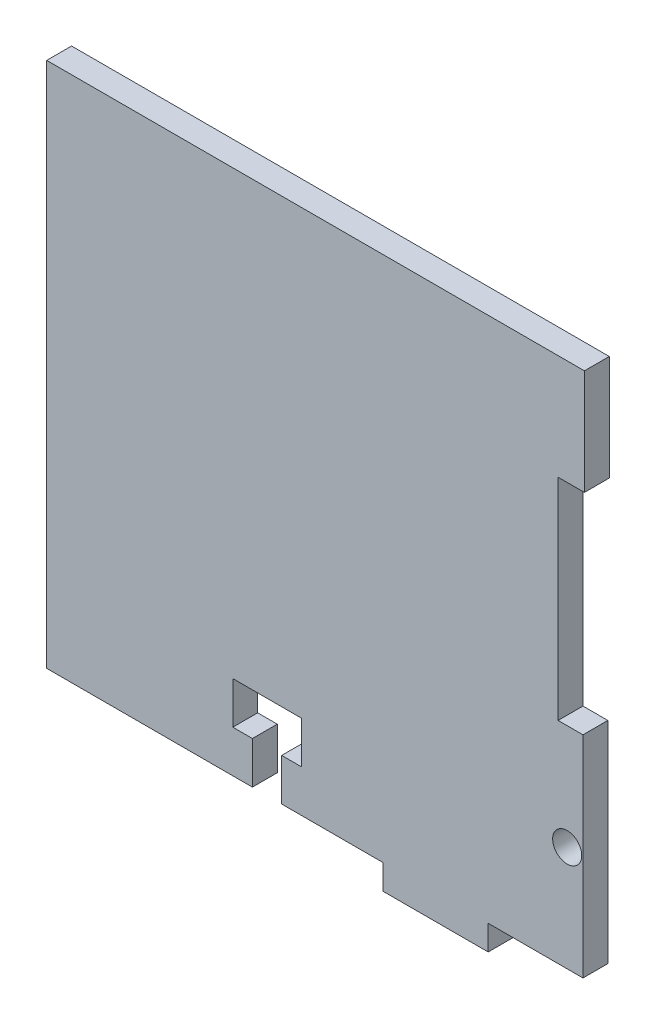
from build123d import *

# Parameters (mm, degrees)
SKETCH1_R           = 1.7526
BOSS_EXTRUDE1_DEPTH = 3


with BuildPart() as part:
    # Sketch1 → Boss-Extrude1 (new body)
    with BuildSketch(Plane.XY):
        Polygon((49.628328589, 31.75), (111.125, 31.75), (114.475, 31.75), (114.475, 19.05), (111.3, 19.05), (111.3, -6.35), (114.3, -6.35), (114.3, -18.229405084), (114.3, -19.870594916), (114.3, -31.75), (111.125, -31.75), (102.87, -31.75), (102.87, -34.75), (90.17, -34.75), (90.17, -31.75), (88.19515, -31.75), (77.9653, -31.75), (77.9653, -26.67), (80.3275, -26.67), (80.3275, -21.59), (72.0725, -21.59), (72.0725, -26.67), (74.4347, -26.67), (74.4347, -31.75), (49.628328589, -31.75), align=None)
        with Locations((112.395, -19.05)):
            Circle(SKETCH1_R, mode=Mode.SUBTRACT)
    extrude(amount=BOSS_EXTRUDE1_DEPTH)


solid = part.part
